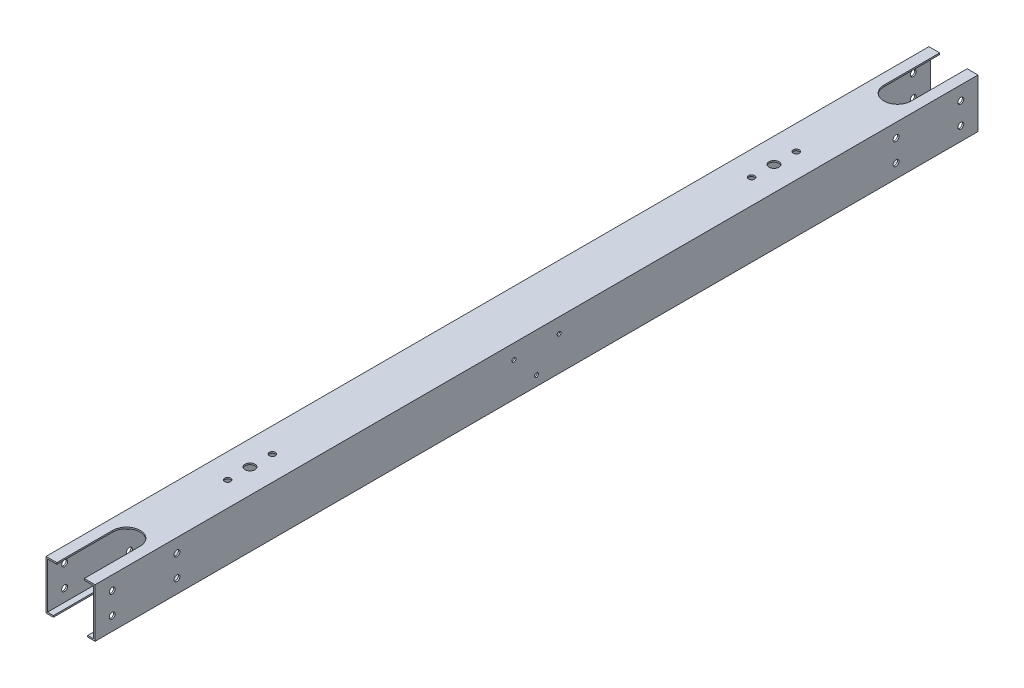
from build123d import *

# Parameters (mm, degrees)
SKETCH1_W           = 50
SKETCH1_H           = 50
SKETCH1_W_2         = 47
SKETCH1_H_2         = 47
BOSS_EXTRUDE1_DEPTH = 900
SKETCH2_R           = 2
CUT_EXTRUDE1_DEPTH  = 59
CUT_EXTRUDE2_DEPTH  = 10
CUT_EXTRUDE3_DEPTH  = 10
SKETCH5_R           = 3
CUT_EXTRUDE4_DEPTH  = 55
SKETCH6_R           = 3.125
SKETCH6_R_2         = 5
CUT_EXTRUDE5_DEPTH  = 70


with BuildPart() as part:
    # Sketch1 → Boss-Extrude1 (new body)
    with BuildSketch(Plane.XY):
        Rectangle(SKETCH1_W, SKETCH1_H)
        Rectangle(SKETCH1_W_2, SKETCH1_H_2, mode=Mode.SUBTRACT)
    extrude(amount=BOSS_EXTRUDE1_DEPTH)

    # Sketch2 → Cut-Extrude1 (cut)
    with BuildSketch(Plane(origin=(25, 0, 0), x_dir=(0, 0, -1), z_dir=(1, 0, 0))):
        with Locations((-450, -15)):
            Circle(SKETCH2_R)
        with Locations((-427, 10)):
            Circle(SKETCH2_R)
        with Locations((-473, 10)):
            Circle(SKETCH2_R)
    extrude(amount=-CUT_EXTRUDE1_DEPTH, mode=Mode.SUBTRACT)

    # Sketch3 → Cut-Extrude2 (cut)
    with BuildSketch(Plane(origin=(0, 25, 0), x_dir=(1, 0, 0), z_dir=(0, 1, 0))):
        with BuildLine():
            Line((14, -843), (14, -913.98611775))
            ThreePointArc((14, -913.98611775), (0, -927.98611775), (-14, -913.98611775))
            Line((-14, -913.98611775), (-14, -843))
            ThreePointArc((-14, -843), (0, -829), (14, -843))
        make_face()
    cut_extrude2 = extrude(amount=-CUT_EXTRUDE2_DEPTH, mode=Mode.SUBTRACT)

    # Sketch4 → Cut-Extrude3 (cut)
    with BuildSketch(Plane.XZ.offset(25)):
        with BuildLine():
            Line((-17.498938419, 850), (-17.498938419, 939.078503923))
            ThreePointArc((-17.498938419, 939.078503923), (0.001061581, 956.578503923), (17.501061581, 939.078503923))
            Line((17.501061581, 939.078503923), (17.501061581, 850))
            ThreePointArc((17.501061581, 850), (0.001061581, 832.5), (-17.498938419, 850))
        make_face()
    cut_extrude3 = extrude(amount=-CUT_EXTRUDE3_DEPTH, mode=Mode.SUBTRACT)

    # Sketch5 → Cut-Extrude4 (cut)
    with BuildSketch(Plane(origin=(25, 0, 0), x_dir=(0, 0, -1), z_dir=(1, 0, 0))):
        with Locations((-882.5, 11)):
            Circle(SKETCH5_R)
        with Locations((-882.5, -11)):
            Circle(SKETCH5_R)
        with Locations((-816.5, -11)):
            Circle(SKETCH5_R)
        with Locations((-816.5, 11)):
            Circle(SKETCH5_R)
    cut_extrude4 = extrude(amount=-CUT_EXTRUDE4_DEPTH, mode=Mode.SUBTRACT)

    # Mirror1: Cut-Extrude2, Cut-Extrude3, Cut-Extrude4 across plane
    add(cut_extrude2.mirror(Plane.XY.offset(450)), mode=Mode.SUBTRACT)
    add(cut_extrude3.mirror(Plane.XY.offset(450)), mode=Mode.SUBTRACT)
    add(cut_extrude4.mirror(Plane.XY.offset(450)), mode=Mode.SUBTRACT)

    # Sketch6 → Cut-Extrude5 (cut)
    with BuildSketch(Plane(origin=(0, 25, 0), x_dir=(1, 0, 0), z_dir=(0, 1, 0))):
        with Locations((0, -694.2275)):
            Circle(SKETCH6_R)
        with Locations((0, -739.8525)):
            Circle(SKETCH6_R)
        with Locations((0, -717.04)):
            Circle(SKETCH6_R_2)
    cut_extrude5 = extrude(amount=-CUT_EXTRUDE5_DEPTH, mode=Mode.SUBTRACT)

    # Mirror2: Cut-Extrude5 across plane
    add(cut_extrude5.mirror(Plane.XY.offset(450)), mode=Mode.SUBTRACT)


solid = part.part
